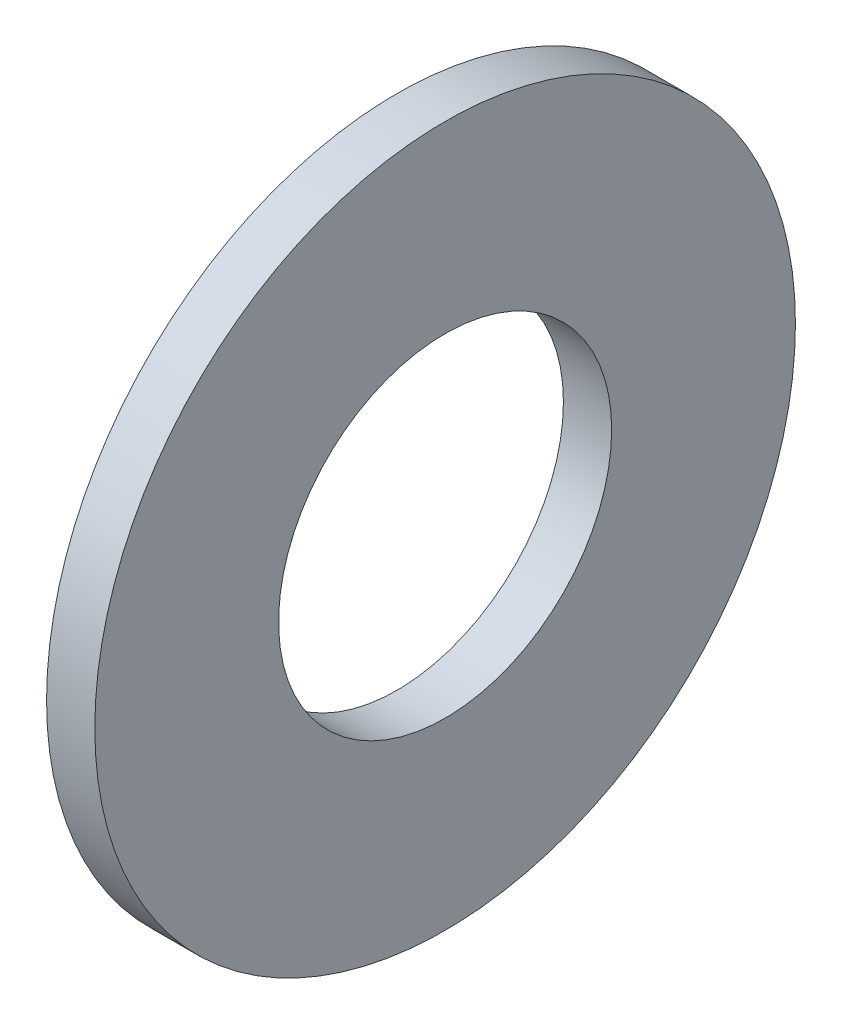
from build123d import *

# Parameters (mm, degrees)
SKETCH1_R           = 30.5
SKETCH1_R_2         = 14.5
BOSS_EXTRUDE1_DEPTH = 4.2


with BuildPart() as part:
    # Sketch1 → Boss-Extrude1 (new body)
    with BuildSketch(Plane(origin=(0, 0, 0), x_dir=(0, 0, -1), z_dir=(1, 0, 0))):
        Circle(SKETCH1_R)
        Circle(SKETCH1_R_2, mode=Mode.SUBTRACT)
    extrude(amount=-BOSS_EXTRUDE1_DEPTH)


solid = part.part
